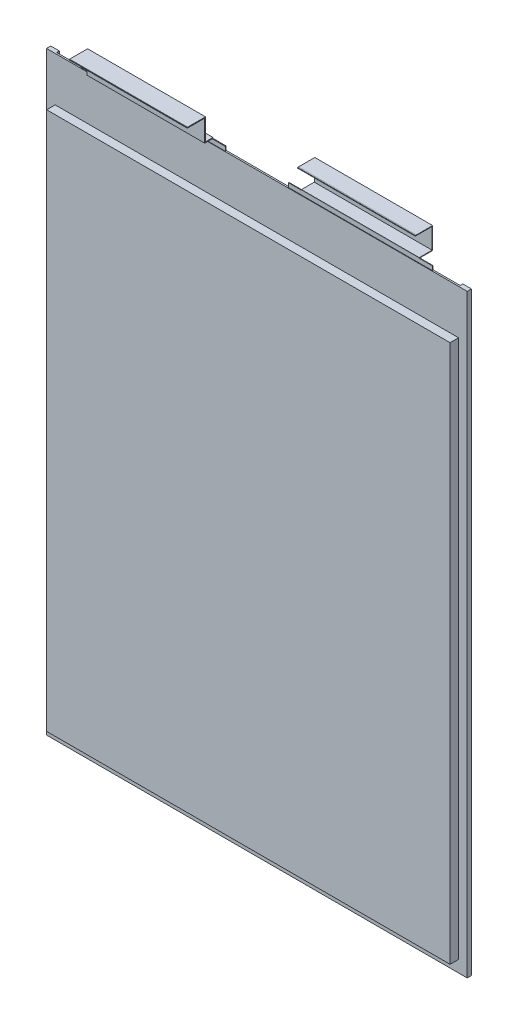
from build123d import *

# Parameters (mm, degrees)
SKETCH1_W                    = 160.6
SKETCH1_H                    = 227
INSULATION_DEPTH             = 0.3
INSULATION_DEPTH_BACK        = 0.3
SKETCH2_W                    = 154
SKETCH2_H                    = 205.5
MAIN_BODY_DEPTH              = 3.55
MAIN_BODY_DEPTH_BACK         = 3.55
SIDE_FOLDS_DEPTH             = 1.016
SKETCH6_W                    = 55
SKETCH6_H                    = 18.6
NEGATIVE_TAB_BASE_DEPTH      = 0.1
NEGATIVE_TAB_BASE_DEPTH_BACK = 0.1
SKETCH7_W                    = 55
SKETCH7_H                    = 18.6
POSITIVE_TAB_BASE_DEPTH      = 0.15
POSITIVE_TAB_BASE_DEPTH_BACK = 0.15
SKETCH110_W                  = 0.3
SKETCH110_H                  = 45
POSITIVE_TAB_DEPTH           = 23.650499994
SKETCH110_ON_SEGMENT_2_W     = 0.3
SKETCH110_ON_SEGMENT_2_H     = 45
POSITIVE_TAB_2_DEPTH         = 49.874449989
SKETCH110_ON_SEGMENT_3_W     = 0.3
SKETCH110_ON_SEGMENT_3_H     = 45
POSITIVE_TAB_3_DEPTH         = 55.260999989
SKETCH110_ON_SEGMENT_4_W     = 0.3
SKETCH110_ON_SEGMENT_4_H     = 45
POSITIVE_TAB_4_DEPTH         = 31.133774994
SKETCH110_ON_SEGMENT_5_W     = 0.3
SKETCH110_ON_SEGMENT_5_H     = 45
POSITIVE_TAB_5_DEPTH         = 1.15
SKETCH113_W                  = 0.2
SKETCH113_H                  = 45
NEGATIVE_TAB_DEPTH           = 23.600222221
SKETCH113_ON_SEGMENT_2_W     = 0.2
SKETCH113_ON_SEGMENT_2_H     = 45
NEGATIVE_TAB_2_DEPTH         = 51.904294442
SKETCH113_ON_SEGMENT_3_W     = 0.2
SKETCH113_ON_SEGMENT_3_H     = 45
NEGATIVE_TAB_3_DEPTH         = 55.060444442
SKETCH113_ON_SEGMENT_4_W     = 0.2
SKETCH113_ON_SEGMENT_4_H     = 45
NEGATIVE_TAB_4_DEPTH         = 30.622297221
SKETCH113_ON_SEGMENT_5_W     = 0.2
SKETCH113_ON_SEGMENT_5_H     = 45
NEGATIVE_TAB_5_DEPTH         = 1.4


with BuildPart() as part:
    # Sketch1 → Insulation (new, two sides)
    with BuildSketch(Plane.XY) as insulation_sk:
        Rectangle(SKETCH1_W, SKETCH1_H)
    extrude(amount=INSULATION_DEPTH)
    extrude(insulation_sk.sketch, amount=-INSULATION_DEPTH_BACK)

    # Sketch2 → Main Body (add, two sides)
    with BuildSketch(Plane.XY) as main_body_sk:
        with Locations((0, -6.25)):
            Rectangle(SKETCH2_W, SKETCH2_H)
    extrude(amount=MAIN_BODY_DEPTH)
    extrude(main_body_sk.sketch, amount=-MAIN_BODY_DEPTH_BACK)

    # Sketch5 → Side Folds (add)
    with BuildSketch(Plane(origin=(0, 0, -0.3), x_dir=(-1, 0, 0), z_dir=(0, 0, -1))):
        Polygon((-77, -109), (-77, 96.5), (-77, 113.5), (-80.3, 113.5), (-80.3, -113.5), (-77, -113.5), align=None)
        Polygon((77, 113.5), (77, 96.5), (77, -109), (77, -113.5), (80.3, -113.5), (80.3, 113.5), align=None)
    extrude(amount=SIDE_FOLDS_DEPTH)

    # Sketch6 → Negative Tab Base (add, two sides)
    with BuildSketch(Plane.XY) as negative_tab_base_sk:
        with Locations((39.3, 105.8)):
            Rectangle(SKETCH6_W, SKETCH6_H)
    extrude(amount=NEGATIVE_TAB_BASE_DEPTH)
    extrude(negative_tab_base_sk.sketch, amount=-NEGATIVE_TAB_BASE_DEPTH_BACK)

    # Sketch7 → Positive Tab Base (add, two sides)
    with BuildSketch(Plane.XY) as positive_tab_base_sk:
        with Locations((-39.7, 105.8)):
            Rectangle(SKETCH7_W, SKETCH7_H)
    extrude(amount=POSITIVE_TAB_BASE_DEPTH)
    extrude(positive_tab_base_sk.sketch, amount=-POSITIVE_TAB_BASE_DEPTH_BACK)


with BuildPart() as body_2:
    # Sketch110 → Positive Tab (new body)
    with BuildSketch(Plane(origin=(-39.7, 115.1, 0), x_dir=(0, 0, -1), z_dir=(0, 1, 0))):
        Rectangle(SKETCH110_W, SKETCH110_H)
    extrude(amount=POSITIVE_TAB_DEPTH)

    # Positive Tab mitre 1
    split(bisect_by=Plane(origin=(-39.7, 115.25, 0), x_dir=(1, 0, 0), z_dir=(0, -0.707106781, -0.707106781)), keep=Keep.TOP)


with BuildPart() as body_3:
    # Sketch110 on segment 2 (carried to segment 2) → Positive Tab 2 (new body)
    with BuildSketch(Plane(origin=(-39.7, 115.25, -23.500499994), x_dir=(0, 1, 0), z_dir=(0, 0, 1))):
        Rectangle(SKETCH110_ON_SEGMENT_2_W, SKETCH110_ON_SEGMENT_2_H)
    extrude(amount=POSITIVE_TAB_2_DEPTH)

    # Positive Tab 2 mitre 1
    split(bisect_by=Plane(origin=(-39.7, 115.25, 0), x_dir=(-1, 0, 0), z_dir=(0, 0.707106781, 0.707106781)), keep=Keep.TOP)

    # Positive Tab 2 mitre 2
    split(bisect_by=Plane(origin=(-39.7, 115.25, 2.87345), x_dir=(1, 0, 0), z_dir=(0, -0.707106781, -0.707106781)), keep=Keep.TOP)


with BuildPart() as body_4:
    # Sketch110 on segment 3 (carried to segment 3) → Positive Tab 3 (new body)
    with BuildSketch(Plane(origin=(-39.7, 91.749500006, 2.87345), x_dir=(0, 0, -1), z_dir=(0, 1, 0))):
        Rectangle(SKETCH110_ON_SEGMENT_3_W, SKETCH110_ON_SEGMENT_3_H)
    extrude(amount=POSITIVE_TAB_3_DEPTH)

    # Positive Tab 3 mitre 1
    split(bisect_by=Plane(origin=(-39.7, 115.25, 2.87345), x_dir=(-1, 0, 0), z_dir=(0, 0.707106781, 0.707106781)), keep=Keep.TOP)

    # Positive Tab 3 mitre 2
    split(bisect_by=Plane(origin=(-39.7, 123.51, 2.87345), x_dir=(1, 0, 0), z_dir=(0, -0.707106781, -0.707106781)), keep=Keep.TOP)


with BuildPart() as body_5:
    # Sketch110 on segment 4 (carried to segment 4) → Positive Tab 4 (new body)
    with BuildSketch(Plane(origin=(-39.7, 123.51, -20.627049994), x_dir=(0, 1, 0), z_dir=(0, 0, 1))):
        Rectangle(SKETCH110_ON_SEGMENT_4_W, SKETCH110_ON_SEGMENT_4_H)
    extrude(amount=POSITIVE_TAB_4_DEPTH)

    # Positive Tab 4 mitre 1
    split(bisect_by=Plane(origin=(-39.7, 123.51, 2.87345), x_dir=(-1, 0, 0), z_dir=(0, 0.707106781, 0.707106781)), keep=Keep.TOP)

    # Positive Tab 4 mitre 2
    split(bisect_by=Plane(origin=(-39.7, 123.51, 9.506725), x_dir=(0, 1, 0), z_dir=(0, 0, -1)), keep=Keep.TOP)


with BuildPart() as body_6:
    # Sketch110 on segment 5 (carried to segment 5) → Positive Tab 5 (new body)
    with BuildSketch(Plane(origin=(-39.7, 123.51, 8.506725), x_dir=(0, 1, 0), z_dir=(0, 0, 1))):
        Rectangle(SKETCH110_ON_SEGMENT_5_W, SKETCH110_ON_SEGMENT_5_H)
    extrude(amount=POSITIVE_TAB_5_DEPTH)

    # Positive Tab 5 mitre 1
    split(bisect_by=Plane(origin=(-39.7, 123.51, 9.506725), x_dir=(0, -1, 0), z_dir=(0, 0, 1)), keep=Keep.TOP)


with BuildPart() as body_7:
    # Sketch113 → Negative Tab (new body)
    with BuildSketch(Plane(origin=(39.3, 115.1, 0), x_dir=(0, 0, -1), z_dir=(0, 1, 0))):
        Rectangle(SKETCH113_W, SKETCH113_H)
    extrude(amount=NEGATIVE_TAB_DEPTH)

    # Negative Tab mitre 1
    split(bisect_by=Plane(origin=(39.3, 115.2, 0), x_dir=(1, 0, 0), z_dir=(0, -0.707106781, 0.707106781)), keep=Keep.TOP)


with BuildPart() as body_8:
    # Sketch113 on segment 2 (carried to segment 2) → Negative Tab 2 (new body)
    with BuildSketch(Plane(origin=(39.3, 115.2, 23.500222221), x_dir=(0, -1, 0), z_dir=(0, 0, -1))):
        Rectangle(SKETCH113_ON_SEGMENT_2_W, SKETCH113_ON_SEGMENT_2_H)
    extrude(amount=NEGATIVE_TAB_2_DEPTH)

    # Negative Tab 2 mitre 1
    split(bisect_by=Plane(origin=(39.3, 115.2, 0), x_dir=(-1, 0, 0), z_dir=(0, 0.707106781, -0.707106781)), keep=Keep.TOP)

    # Negative Tab 2 mitre 2
    split(bisect_by=Plane(origin=(39.3, 115.2, -4.90385), x_dir=(1, 0, 0), z_dir=(0, -0.707106781, 0.707106781)), keep=Keep.TOP)


with BuildPart() as body_9:
    # Sketch113 on segment 3 (carried to segment 3) → Negative Tab 3 (new body)
    with BuildSketch(Plane(origin=(39.3, 91.699777779, -4.90385), x_dir=(0, 0, -1), z_dir=(0, 1, 0))):
        Rectangle(SKETCH113_ON_SEGMENT_3_W, SKETCH113_ON_SEGMENT_3_H)
    extrude(amount=NEGATIVE_TAB_3_DEPTH)

    # Negative Tab 3 mitre 1
    split(bisect_by=Plane(origin=(39.3, 115.2, -4.90385), x_dir=(-1, 0, 0), z_dir=(0, 0.707106781, -0.707106781)), keep=Keep.TOP)

    # Negative Tab 3 mitre 2
    split(bisect_by=Plane(origin=(39.3, 123.26, -4.90385), x_dir=(1, 0, 0), z_dir=(0, -0.707106781, -0.707106781)), keep=Keep.TOP)


with BuildPart() as body_10:
    # Sketch113 on segment 4 (carried to segment 4) → Negative Tab 4 (new body)
    with BuildSketch(Plane(origin=(39.3, 123.26, -28.404072221), x_dir=(0, 1, 0), z_dir=(0, 0, 1))):
        Rectangle(SKETCH113_ON_SEGMENT_4_W, SKETCH113_ON_SEGMENT_4_H)
    extrude(amount=NEGATIVE_TAB_4_DEPTH)

    # Negative Tab 4 mitre 1
    split(bisect_by=Plane(origin=(39.3, 123.26, -4.90385), x_dir=(-1, 0, 0), z_dir=(0, 0.707106781, 0.707106781)), keep=Keep.TOP)

    # Negative Tab 4 mitre 2
    split(bisect_by=Plane(origin=(39.3, 123.26, 1.218225), x_dir=(0, 1, 0), z_dir=(0, 0, -1)), keep=Keep.TOP)


with BuildPart() as body_11:
    # Sketch113 on segment 5 (carried to segment 5) → Negative Tab 5 (new body)
    with BuildSketch(Plane(origin=(39.3, 123.26, 0.218225), x_dir=(0, 1, 0), z_dir=(0, 0, 1))):
        Rectangle(SKETCH113_ON_SEGMENT_5_W, SKETCH113_ON_SEGMENT_5_H)
    extrude(amount=NEGATIVE_TAB_5_DEPTH)

    # Negative Tab 5 mitre 1
    split(bisect_by=Plane(origin=(39.3, 123.26, 1.218225), x_dir=(0, -1, 0), z_dir=(0, 0, 1)), keep=Keep.TOP)


solid = Compound([part.part, body_2.part, body_3.part, body_4.part, body_5.part, body_6.part, body_7.part, body_8.part, body_9.part, body_10.part, body_11.part])
